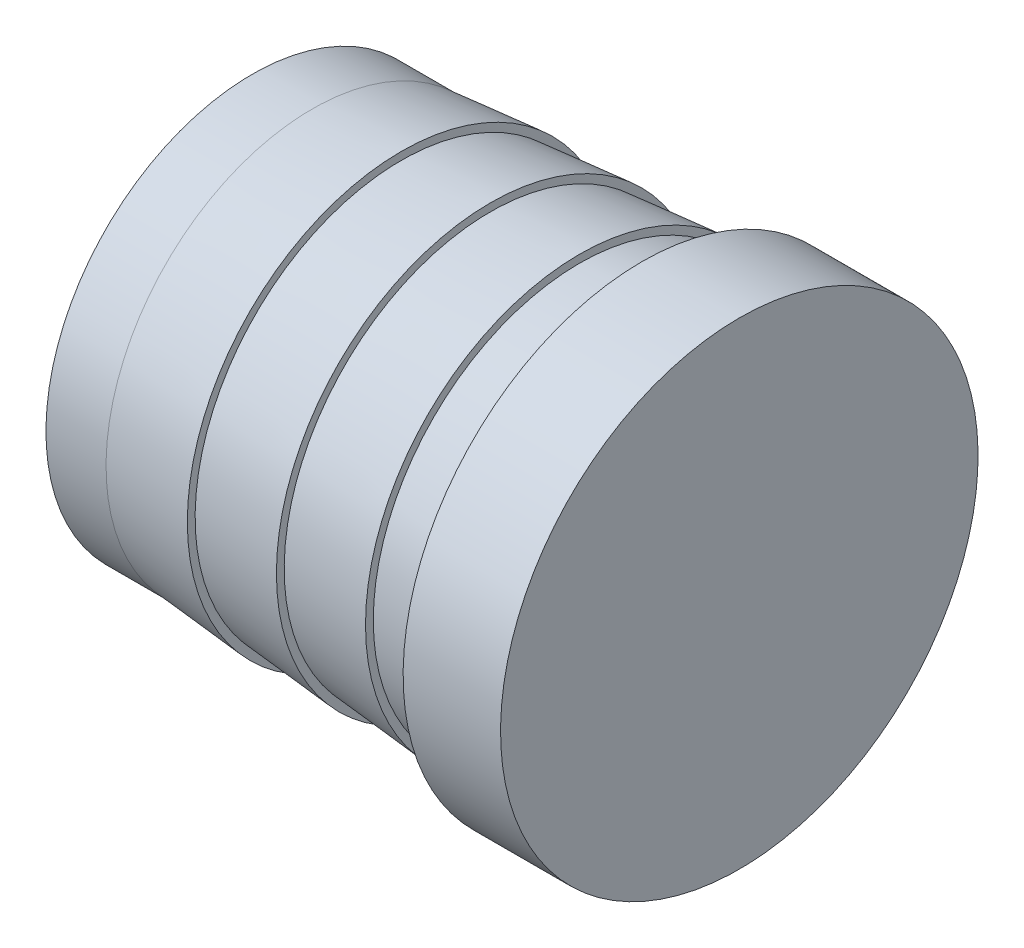
from build123d import *

# Parameters (mm, degrees)
SKETCH2_R           = 23.3426
BOSS_EXTRUDE1_DEPTH = 9.525


with BuildPart() as part:
    # Sketch1 → Revolve1 (revolve)
    with BuildSketch(Plane.XY):
        Polygon((-47.625, 14.2875), (-9.525, 14.2875), (-9.525, 20.16125), (-6.912450581, 20.16125), (-6.912450581, 20.92325), (-15.622150436, 20.16125), (-15.622150436, 20.92325), (-24.331850291, 20.16125), (-24.331850291, 20.92325), (-33.041550145, 20.16125), (-33.041550145, 20.92325), (-41.75125, 20.16125), (-47.625, 20.16125), align=None)
    revolve(axis=Axis((-47.625, 0, 0), (1, 0, 0)))

    # Sketch2 → Boss-Extrude1 (add)
    with BuildSketch(Plane(origin=(-9.525, 0, 0), x_dir=(0, 0, -1), z_dir=(1, 0, 0))):
        Circle(SKETCH2_R)
    extrude(amount=BOSS_EXTRUDE1_DEPTH)


solid = part.part
